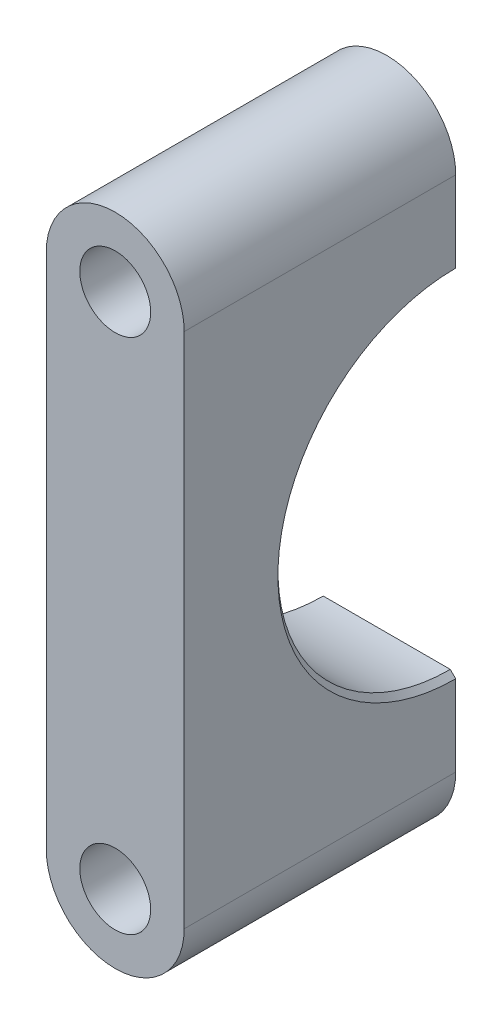
from build123d import *

# Parameters (mm, degrees)
SKETCH2_R           = 3.2639
BOSS_EXTRUDE1_DEPTH = 25.0031
SKETCH3_R           = 15.875
CUT_EXTRUDE1_DEPTH  = 13.7
CHAMFER1_SIZE       = 0.5
CHAMFER2_SIZE       = 0.5


with BuildPart() as part:
    # Sketch2 → Boss-Extrude1 (new body)
    with BuildSketch(Plane.XY):
        with BuildLine():
            Line((-6.35, 23.8125), (-6.35, -23.8114))
            ThreePointArc((-6.35, -23.8114), (0, -30.1614), (6.35, -23.8114))
            Line((6.35, -23.8114), (6.35, 23.8125))
            ThreePointArc((6.35, 23.8125), (0, 30.1625), (-6.35, 23.8125))
        make_face()
        with Locations((0, -23.8114)):
            Circle(SKETCH2_R, mode=Mode.SUBTRACT)
        with Locations((0, 23.8125)):
            Circle(SKETCH2_R, mode=Mode.SUBTRACT)
    extrude(amount=BOSS_EXTRUDE1_DEPTH)

    # Sketch3 → Cut-Extrude1 (cut, through all)
    with BuildSketch(Plane(origin=(6.35, 0, 0), x_dir=(0, 0, -1), z_dir=(1, 0, 0))):
        Circle(SKETCH3_R)
    extrude(amount=-CUT_EXTRUDE1_DEPTH, mode=Mode.SUBTRACT)

    # Chamfer1
    chamfer1_edges = [part.edges().sort_by_distance(p)[0] for p in [
        (6.35, 0, 15.875),
    ]]
    chamfer(chamfer1_edges, length=CHAMFER1_SIZE)

    # Chamfer2
    chamfer2_edges = [part.edges().sort_by_distance(p)[0] for p in [
        (-6.35, 0, 15.875),
    ]]
    chamfer(chamfer2_edges, length=CHAMFER2_SIZE)


solid = part.part
